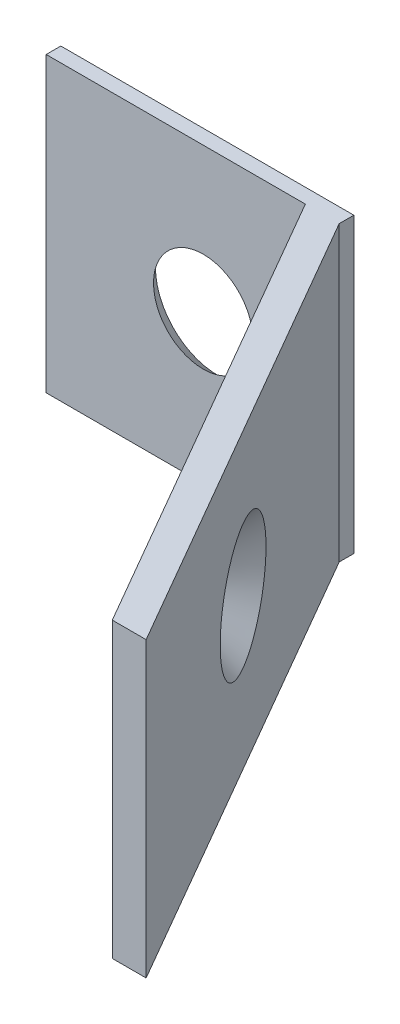
from build123d import *

# Parameters (mm, degrees)
SKETCH2_W                                         = 10
SKETCH2_H                                         = 10
BOSS_EXTRUDE1_DEPTH                               = 0.5
BOSS_EXTRUDE2_DEPTH                               = 10
CSK_FOR_1_FLAT_HEAD_SOCKET_CAP_SCREW1_D           = 2.0574
CSK_FOR_1_FLAT_HEAD_SOCKET_CAP_SCREW1_CSINK_D     = 4.2672
CSK_FOR_1_FLAT_HEAD_SOCKET_CAP_SCREW1_CSINK_ANGLE = 82
CSK_FOR_1_FLAT_HEAD_SOCKET_CAP_SCREW2_D           = 2.0574
CSK_FOR_1_FLAT_HEAD_SOCKET_CAP_SCREW2_CSINK_D     = 4.2672
CSK_FOR_1_FLAT_HEAD_SOCKET_CAP_SCREW2_CSINK_ANGLE = 82


with BuildPart() as part:
    # Sketch2 → Boss-Extrude1 (new body)
    with BuildSketch(Plane.XY):
        with Locations((5, -5)):
            Rectangle(SKETCH2_W, SKETCH2_H)
    extrude(amount=BOSS_EXTRUDE1_DEPTH)

    # Sketch3 → Boss-Extrude2 (add)
    with BuildSketch(Plane.XZ.offset(10)):
        Polygon((8.845299462, 0.5), (17.845299462, 16.088457268), (19, 16.088457268), (10, 0.5), align=None)
    extrude(amount=-BOSS_EXTRUDE2_DEPTH)

    # CSK for #1 Flat Head Socket Cap Screw1 (through all)
    with Locations(Plane(origin=(0, 0, 0), x_dir=(-1, 0, 0), z_dir=(0, 0, -1))):
        with Locations((-5.362516401, -4.921292394)):
            CounterSinkHole(CSK_FOR_1_FLAT_HEAD_SOCKET_CAP_SCREW1_D / 2, CSK_FOR_1_FLAT_HEAD_SOCKET_CAP_SCREW1_CSINK_D / 2, counter_sink_angle=CSK_FOR_1_FLAT_HEAD_SOCKET_CAP_SCREW1_CSINK_ANGLE)

    # CSK for #1 Flat Head Socket Cap Screw2 (through all)
    with Locations(Plane(origin=(7.283493649, 0, -4.205127019), x_dir=(-0.5, 0, -0.866025404), z_dir=(0.866025404, 0, -0.5))):
        with Locations((-14.39146791, -4.879407471)):
            CounterSinkHole(CSK_FOR_1_FLAT_HEAD_SOCKET_CAP_SCREW2_D / 2, CSK_FOR_1_FLAT_HEAD_SOCKET_CAP_SCREW2_CSINK_D / 2, counter_sink_angle=CSK_FOR_1_FLAT_HEAD_SOCKET_CAP_SCREW2_CSINK_ANGLE)


solid = part.part
